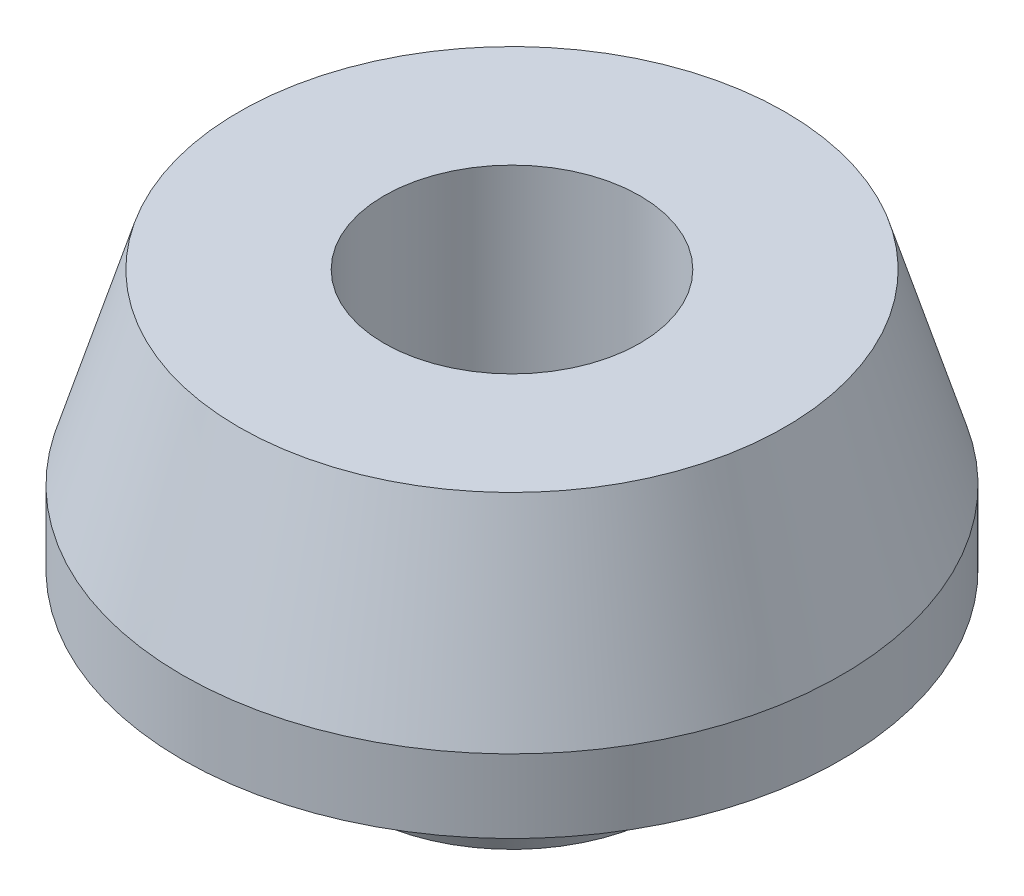
from build123d import *


with BuildPart() as part:
    # Sketch1 → Revolve1 (revolve)
    with BuildSketch(Plane.XY):
        Polygon((4.8, 0), (5.8, 0), (7.619851171, 5), (12.369851171, 5), (12.369851171, 7.75), (10.25, 14.75), (4.8, 14.75), align=None)
    revolve(axis=Axis((0, 0, 0), (0, 1, 0)))


solid = part.part
